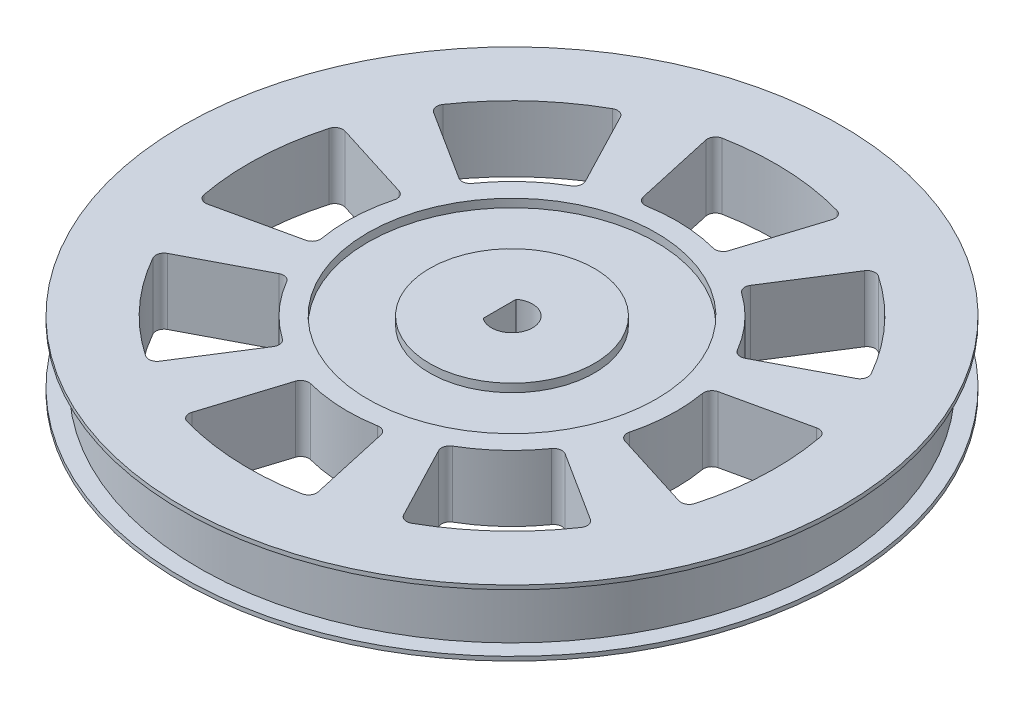
from build123d import *

# Parameters (mm, degrees)
CUT_EXTRUDE1_REACH = 10
CUT_EXTRUDE2_REACH = 10


with BuildPart() as part:
    # Sketch1 → Revolve3 (revolve)
    with BuildSketch(Plane.XY):
        Polygon((40, 4), (37, 4), (17.5, 4), (17.5, 3), (10, 3), (10, 4), (0, 4), (0, -4), (10, -4), (10, -3), (17.5, -3), (17.5, -4), (37, -4), (40, -4), (40, -3.5), (38, -3.5), (38, 3.5), (40, 3.5), align=None)
    revolve(axis=Axis((0, 4, 0), (0, -1, 0)))

    # Sketch2 → Cut-Extrude1 (cut, up to next)
    with BuildSketch(Plane(origin=(0, 4, 0), x_dir=(1, 0, 0), z_dir=(0, 1, 0)), mode=Mode.PRIVATE) as cut_extrude1_sk1:
        with BuildLine():
            ThreePointArc((2.5, 0), (1.118033989, 2.236067977), (-1.5, 2))
            Line((-1.5, 2), (-1.5, -2))
            ThreePointArc((-1.5, -2), (1.118033989, -2.236067977), (2.5, 0))
        make_face()
    cut_extrude1_tool1 = extrude(cut_extrude1_sk1.sketch, amount=-CUT_EXTRUDE1_REACH, mode=Mode.PRIVATE) & part.part
    add(cut_extrude1_tool1.solids().sort_by_distance((0.316718, 4, 0))[0], mode=Mode.SUBTRACT)

    # Sketch3 → Cut-Extrude2 (cut, up to next)
    with BuildSketch(Plane(origin=(0, 4, 0), x_dir=(1, 0, 0), z_dir=(0, 1, 0)), mode=Mode.PRIVATE) as cut_extrude2_sk1:
        with BuildLine():
            Line((4.553448892, -20.475988454), (6.725889759, -30.245039378))
            ThreePointArc((6.725889759, -30.245039378), (6.584709324, -31.012405912), (5.935210643, -31.444765457))
            ThreePointArc((5.935210643, -31.444765457), (-1.374941712, -31.970447843), (-8.612970493, -30.81909699))
            ThreePointArc((-8.612970493, -30.81909699), (-9.22295101, -30.33257147), (-9.297728295, -29.555917319))
            Line((-9.297728295, -29.555917319), (-6.294591812, -20.009450615))
            ThreePointArc((-6.294591812, -20.009450615), (-5.823993451, -19.434086857), (-5.08636065, -19.342412862))
            ThreePointArc((-5.08636065, -19.342412862), (-0.85933857, -19.981529902), (3.406947089, -19.707681536))
            ThreePointArc((3.406947089, -19.707681536), (4.133985694, -19.862346135), (4.553448892, -20.475988454))
        make_face()
    cut_extrude2_tool1 = extrude(cut_extrude2_sk1.sketch, amount=-CUT_EXTRUDE2_REACH, mode=Mode.PRIVATE) & part.part
    add(cut_extrude2_tool1.solids().sort_by_distance((-1.124173, 4, 26.139518))[0], mode=Mode.SUBTRACT)
    # Sketch3 → Cut-Extrude2 (cut, up to next)
    with BuildSketch(Plane(origin=(0, 4, 0), x_dir=(1, 0, 0), z_dir=(0, 1, 0)), mode=Mode.PRIVATE) as cut_extrude2_sk2:
        with BuildLine():
            Line((-18.599766773, -9.697869663), (-27.473676287, -14.324702834))
            ThreePointArc((-27.473676287, -14.324702834), (-27.969978179, -14.926755776), (-27.882682314, -15.70210263))
            ThreePointArc((-27.882682314, -15.70210263), (-23.578751076, -21.634289859), (-18.037979194, -26.431634581))
            ThreePointArc((-18.037979194, -26.431634581), (-17.272989906, -26.585175136), (-16.630550183, -26.142394699))
            Line((-16.630550183, -26.142394699), (-11.258935698, -17.698484877))
            ThreePointArc((-11.258935698, -17.698484877), (-11.121630324, -16.96796896), (-11.526359866, -16.344510646))
            ThreePointArc((-11.526359866, -16.344510646), (-14.736719422, -13.521431162), (-17.273751407, -10.080551193))
            ThreePointArc((-17.273751407, -10.080551193), (-17.860159866, -9.62378934), (-18.599766773, -9.697869663))
        make_face()
    cut_extrude2_tool2 = extrude(cut_extrude2_sk2.sketch, amount=-CUT_EXTRUDE2_REACH, mode=Mode.PRIVATE) & part.part
    add(cut_extrude2_tool2.solids().sort_by_distance((-19.278341, 4, 17.68852))[0], mode=Mode.SUBTRACT)
    # Sketch3 → Cut-Extrude2 (cut, up to next)
    with BuildSketch(Plane(origin=(0, 4, 0), x_dir=(1, 0, 0), z_dir=(0, 1, 0)), mode=Mode.PRIVATE) as cut_extrude2_sk3:
        with BuildLine():
            Line((-20.009450615, 6.294591812), (-29.555917319, 9.297728295))
            ThreePointArc((-29.555917319, 9.297728295), (-30.33257147, 9.22295101), (-30.81909699, 8.612970493))
            ThreePointArc((-30.81909699, 8.612970493), (-31.970447843, 1.374941712), (-31.444765457, -5.935210643))
            ThreePointArc((-31.444765457, -5.935210643), (-31.012405912, -6.584709324), (-30.245039378, -6.725889759))
            Line((-30.245039378, -6.725889759), (-20.475988454, -4.553448892))
            ThreePointArc((-20.475988454, -4.553448892), (-19.862346135, -4.133985694), (-19.707681536, -3.406947089))
            ThreePointArc((-19.707681536, -3.406947089), (-19.981529902, 0.85933857), (-19.342412862, 5.08636065))
            ThreePointArc((-19.342412862, 5.08636065), (-19.434086857, 5.823993451), (-20.009450615, 6.294591812))
        make_face()
    cut_extrude2_tool3 = extrude(cut_extrude2_sk3.sketch, amount=-CUT_EXTRUDE2_REACH, mode=Mode.PRIVATE) & part.part
    add(cut_extrude2_tool3.solids().sort_by_distance((-26.139518, 4, -1.124173))[0], mode=Mode.SUBTRACT)
    # Sketch3 → Cut-Extrude2 (cut, up to next)
    with BuildSketch(Plane(origin=(0, 4, 0), x_dir=(1, 0, 0), z_dir=(0, 1, 0)), mode=Mode.PRIVATE) as cut_extrude2_sk4:
        with BuildLine():
            Line((-9.697869663, 18.599766773), (-14.324702834, 27.473676287))
            ThreePointArc((-14.324702834, 27.473676287), (-14.926755776, 27.969978179), (-15.70210263, 27.882682314))
            ThreePointArc((-15.70210263, 27.882682314), (-21.634289859, 23.578751076), (-26.431634581, 18.037979194))
            ThreePointArc((-26.431634581, 18.037979194), (-26.585175136, 17.272989906), (-26.142394699, 16.630550183))
            Line((-26.142394699, 16.630550183), (-17.698484877, 11.258935698))
            ThreePointArc((-17.698484877, 11.258935698), (-16.96796896, 11.121630324), (-16.344510646, 11.526359866))
            ThreePointArc((-16.344510646, 11.526359866), (-13.521431162, 14.736719422), (-10.080551193, 17.273751407))
            ThreePointArc((-10.080551193, 17.273751407), (-9.62378934, 17.860159866), (-9.697869663, 18.599766773))
        make_face()
    cut_extrude2_tool4 = extrude(cut_extrude2_sk4.sketch, amount=-CUT_EXTRUDE2_REACH, mode=Mode.PRIVATE) & part.part
    add(cut_extrude2_tool4.solids().sort_by_distance((-17.68852, 4, -19.278341))[0], mode=Mode.SUBTRACT)
    # Sketch3 → Cut-Extrude2 (cut, up to next)
    with BuildSketch(Plane(origin=(0, 4, 0), x_dir=(1, 0, 0), z_dir=(0, 1, 0)), mode=Mode.PRIVATE) as cut_extrude2_sk5:
        with BuildLine():
            Line((6.294591812, 20.009450615), (9.297728295, 29.555917319))
            ThreePointArc((9.297728295, 29.555917319), (9.22295101, 30.33257147), (8.612970493, 30.81909699))
            ThreePointArc((8.612970493, 30.81909699), (1.374941712, 31.970447843), (-5.935210643, 31.444765457))
            ThreePointArc((-5.935210643, 31.444765457), (-6.584709324, 31.012405912), (-6.725889759, 30.245039378))
            Line((-6.725889759, 30.245039378), (-4.553448892, 20.475988454))
            ThreePointArc((-4.553448892, 20.475988454), (-4.133985694, 19.862346135), (-3.406947089, 19.707681536))
            ThreePointArc((-3.406947089, 19.707681536), (0.85933857, 19.981529902), (5.08636065, 19.342412862))
            ThreePointArc((5.08636065, 19.342412862), (5.823993451, 19.434086857), (6.294591812, 20.009450615))
        make_face()
    cut_extrude2_tool5 = extrude(cut_extrude2_sk5.sketch, amount=-CUT_EXTRUDE2_REACH, mode=Mode.PRIVATE) & part.part
    add(cut_extrude2_tool5.solids().sort_by_distance((1.124173, 4, -26.139518))[0], mode=Mode.SUBTRACT)
    # Sketch3 → Cut-Extrude2 (cut, up to next)
    with BuildSketch(Plane(origin=(0, 4, 0), x_dir=(1, 0, 0), z_dir=(0, 1, 0)), mode=Mode.PRIVATE) as cut_extrude2_sk6:
        with BuildLine():
            Line((18.599766773, 9.697869663), (27.473676287, 14.324702834))
            ThreePointArc((27.473676287, 14.324702834), (27.969978179, 14.926755776), (27.882682314, 15.70210263))
            ThreePointArc((27.882682314, 15.70210263), (23.578751076, 21.634289859), (18.037979194, 26.431634581))
            ThreePointArc((18.037979194, 26.431634581), (17.272989906, 26.585175136), (16.630550183, 26.142394699))
            Line((16.630550183, 26.142394699), (11.258935698, 17.698484877))
            ThreePointArc((11.258935698, 17.698484877), (11.121630324, 16.96796896), (11.526359866, 16.344510646))
            ThreePointArc((11.526359866, 16.344510646), (14.736719422, 13.521431162), (17.273751407, 10.080551193))
            ThreePointArc((17.273751407, 10.080551193), (17.860159866, 9.62378934), (18.599766773, 9.697869663))
        make_face()
    cut_extrude2_tool6 = extrude(cut_extrude2_sk6.sketch, amount=-CUT_EXTRUDE2_REACH, mode=Mode.PRIVATE) & part.part
    add(cut_extrude2_tool6.solids().sort_by_distance((19.278341, 4, -17.68852))[0], mode=Mode.SUBTRACT)
    # Sketch3 → Cut-Extrude2 (cut, up to next)
    with BuildSketch(Plane(origin=(0, 4, 0), x_dir=(1, 0, 0), z_dir=(0, 1, 0)), mode=Mode.PRIVATE) as cut_extrude2_sk7:
        with BuildLine():
            Line((20.009450615, -6.294591812), (29.555917319, -9.297728295))
            ThreePointArc((29.555917319, -9.297728295), (30.33257147, -9.22295101), (30.81909699, -8.612970493))
            ThreePointArc((30.81909699, -8.612970493), (31.970447843, -1.374941712), (31.444765457, 5.935210643))
            ThreePointArc((31.444765457, 5.935210643), (31.012405912, 6.584709324), (30.245039378, 6.725889759))
            Line((30.245039378, 6.725889759), (20.475988454, 4.553448892))
            ThreePointArc((20.475988454, 4.553448892), (19.862346135, 4.133985694), (19.707681536, 3.406947089))
            ThreePointArc((19.707681536, 3.406947089), (19.981529902, -0.85933857), (19.342412862, -5.08636065))
            ThreePointArc((19.342412862, -5.08636065), (19.434086857, -5.823993451), (20.009450615, -6.294591812))
        make_face()
    cut_extrude2_tool7 = extrude(cut_extrude2_sk7.sketch, amount=-CUT_EXTRUDE2_REACH, mode=Mode.PRIVATE) & part.part
    add(cut_extrude2_tool7.solids().sort_by_distance((26.139518, 4, 1.124173))[0], mode=Mode.SUBTRACT)
    # Sketch3 → Cut-Extrude2 (cut, up to next)
    with BuildSketch(Plane(origin=(0, 4, 0), x_dir=(1, 0, 0), z_dir=(0, 1, 0)), mode=Mode.PRIVATE) as cut_extrude2_sk8:
        with BuildLine():
            Line((9.697869663, -18.599766773), (14.324702834, -27.473676287))
            ThreePointArc((14.324702834, -27.473676287), (14.926755776, -27.969978179), (15.70210263, -27.882682314))
            ThreePointArc((15.70210263, -27.882682314), (21.634289859, -23.578751076), (26.431634581, -18.037979194))
            ThreePointArc((26.431634581, -18.037979194), (26.585175136, -17.272989906), (26.142394699, -16.630550183))
            Line((26.142394699, -16.630550183), (17.698484877, -11.258935698))
            ThreePointArc((17.698484877, -11.258935698), (16.96796896, -11.121630324), (16.344510646, -11.526359866))
            ThreePointArc((16.344510646, -11.526359866), (13.521431162, -14.736719422), (10.080551193, -17.273751407))
            ThreePointArc((10.080551193, -17.273751407), (9.62378934, -17.860159866), (9.697869663, -18.599766773))
        make_face()
    cut_extrude2_tool8 = extrude(cut_extrude2_sk8.sketch, amount=-CUT_EXTRUDE2_REACH, mode=Mode.PRIVATE) & part.part
    add(cut_extrude2_tool8.solids().sort_by_distance((17.68852, 4, 19.278341))[0], mode=Mode.SUBTRACT)


solid = part.part
